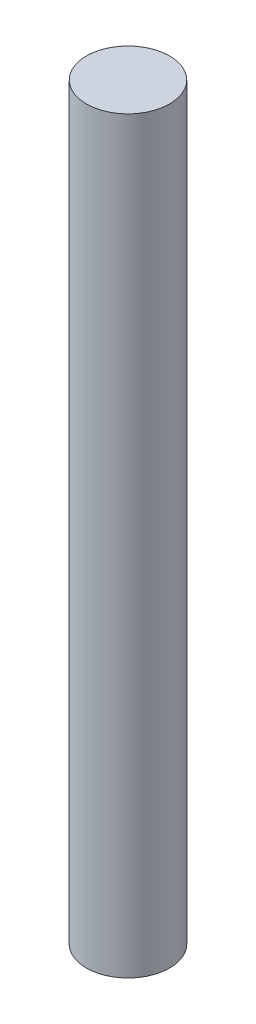
from build123d import *

# Parameters (mm, degrees)
SKIZZE1_R                       = 1
AUFSATZ_LINEAR_AUSTRAGEN1_DEPTH = 18


with BuildPart() as part:
    # Skizze1 → Aufsatz-Linear austragen1 (new body)
    with BuildSketch(Plane(origin=(0, 0, 0), x_dir=(1, 0, 0), z_dir=(0, 1, 0))):
        Circle(SKIZZE1_R)
    extrude(amount=AUFSATZ_LINEAR_AUSTRAGEN1_DEPTH)


solid = part.part
